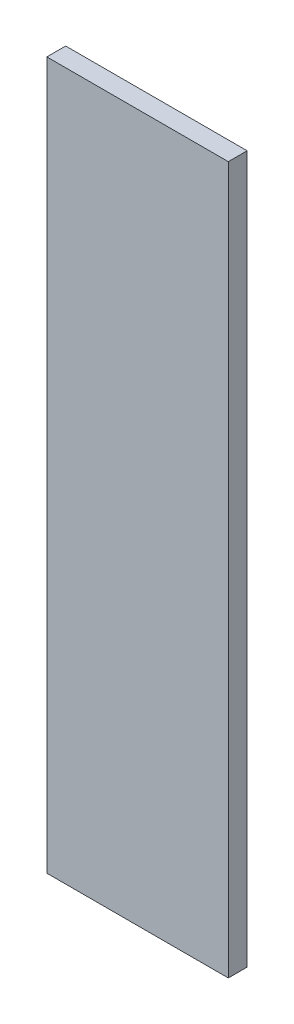
from build123d import *

# Parameters (mm, degrees)
SCHIZZO1_W                   = 7.7
SCHIZZO1_H                   = 30
ESTRUSIONE_ESTRUSIONE1_DEPTH = 0.8


with BuildPart() as part:
    # Schizzo1 → Estrusione-Estrusione1 (new body)
    with BuildSketch(Plane.XY):
        Rectangle(SCHIZZO1_W, SCHIZZO1_H)
    extrude(amount=ESTRUSIONE_ESTRUSIONE1_DEPTH)


solid = part.part
